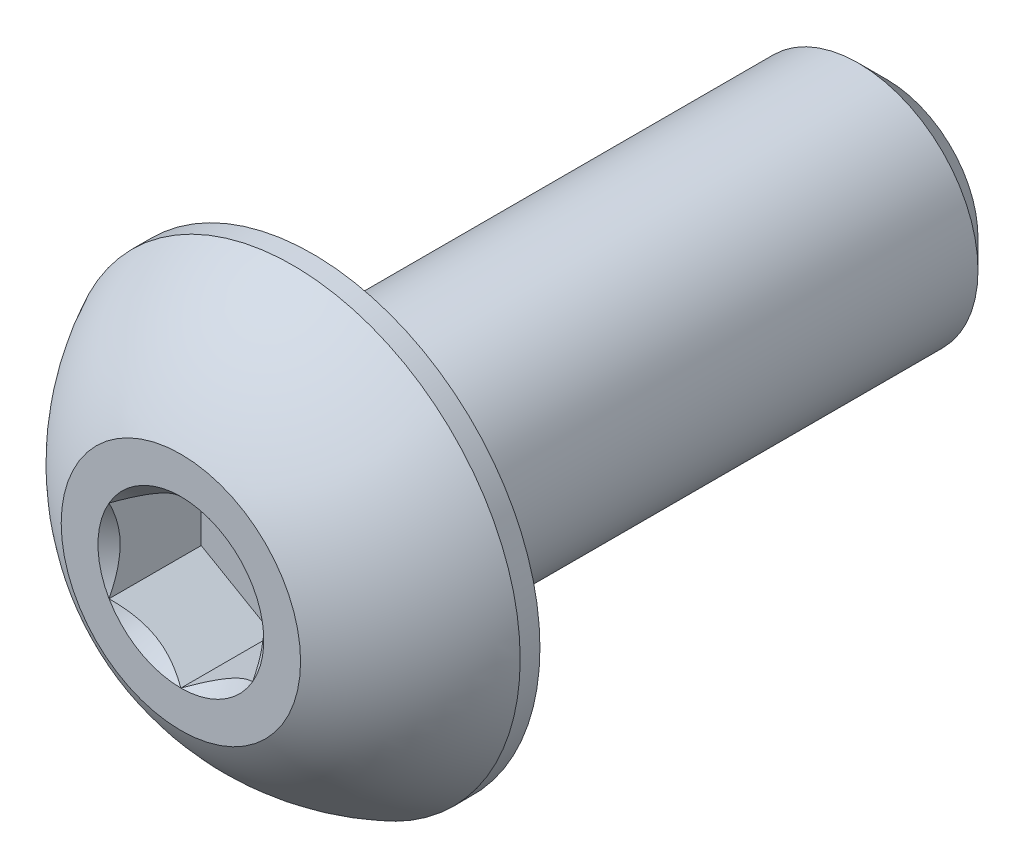
from build123d import *

# Parameters (mm, degrees)
SKETCH1_W          = 12
SKETCH1_H          = 2.5
CHAMFER1_SIZE      = 0.6
CUT_EXTRUDE2_DEPTH = 1.925


with BuildPart() as part:
    # Sketch1 → Revolve1 (revolve)
    with BuildSketch(Plane(origin=(0, 0, 0), x_dir=(0, 0, -1), z_dir=(1, 0, 0))):
        with Locations((8.75, 1.25)):
            Rectangle(SKETCH1_W, SKETCH1_H)
    revolve(axis=Axis((0, 0, -14.75), (0, 0, 1)))

    # Chamfer1
    chamfer1_edges = [part.edges().sort_by_distance(p)[0] for p in [
        (0, -2.5, -14.75),
    ]]
    chamfer(chamfer1_edges, length=CHAMFER1_SIZE)

    # Sketch7 → Revolve2 (revolve)
    with BuildSketch(Plane(origin=(0, 0, 0), x_dir=(0, 0, -1), z_dir=(1, 0, 0))):
        with BuildLine():
            Line((2.3375, 4.75), (2.75, 4.75))
            Line((2.75, 4.75), (2.75, 0))
            Line((2.75, 0), (0, 0))
            Line((0, 0), (0, 2.5))
            ThreePointArc((0, 2.5), (0.991875183, 3.808753282), (2.3375, 4.75))
        make_face()
    revolve(axis=Axis((0, 0, 0), (0, 0, -1)))

    # Sketch5 → Cut-Extrude2 (cut)
    with BuildSketch(Plane.XY):
        Polygon((1.5, -0.866025404), (1.5, 0.866025404), (0, 1.732050808), (-1.5, 0.866025404), (-1.5, -0.866025404), (0, -1.732050808), align=None)
    extrude(amount=-CUT_EXTRUDE2_DEPTH, mode=Mode.SUBTRACT)

    # Cut-Extrude3 cone 1 section (through the dimple's axis) → Cut-Extrude3 (revolve, cut)
    with BuildSketch(Plane(origin=(0, 0, 0), x_dir=(0, -1, 0), z_dir=(1, 0, 0))):
        Polygon((0, 0), (1.732050808, 0), (0, 1.732050808), align=None)
    revolve(axis=Axis((0, 0, 0), (0, 0, -1)), mode=Mode.SUBTRACT)


solid = part.part
